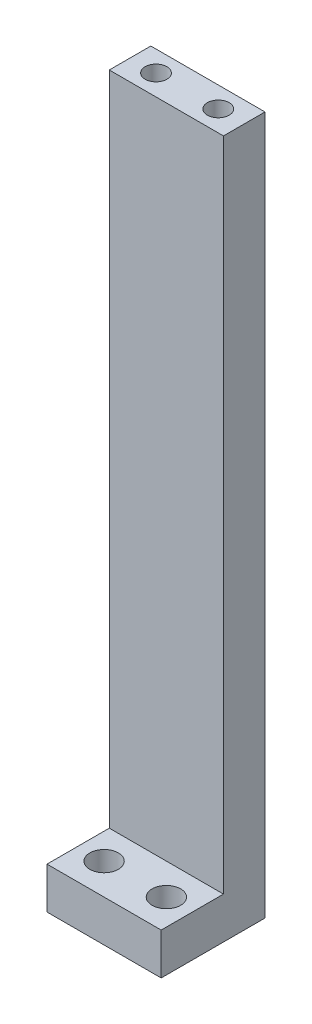
from build123d import *

# Parameters (mm, degrees)
SKETCH_1_W             = 22
SKETCH_1_H             = 134.5
EXTRUDE_1_DEPTH        = 8
HOLE_WIZARD_M5_1_D     = 4.2
HOLE_WIZARD_M5_1_DEPTH = 12.4
HOLE_WIZARD_M5_1_TIP   = 1.2618073
SKETCH_6_W             = 22
SKETCH_6_H             = 8
EXTRUDE_2_DEPTH        = 12
SKETCH_7_R             = 2.75
CUT_EXTRUDE_1_DEPTH    = 9


with BuildPart() as part:
    # 草图1 → 凸台-拉伸1 (new body)
    with BuildSketch(Plane.XY):
        with Locations((11, 67.25)):
            Rectangle(SKETCH_1_W, SKETCH_1_H)
    extrude(amount=EXTRUDE_1_DEPTH)

    # M5 螺纹孔1
    with Locations(Plane(origin=(0, 134.5, 0), x_dir=(1, 0, 0), z_dir=(0, 1, 0))):
        with Locations((17, -4), (5, -4)):
            Hole(HOLE_WIZARD_M5_1_D / 2, depth=HOLE_WIZARD_M5_1_DEPTH)
            with Locations((0, 0, -(HOLE_WIZARD_M5_1_DEPTH + HOLE_WIZARD_M5_1_TIP / 2))):  # 118° drill point
                Cone(0, HOLE_WIZARD_M5_1_D / 2, HOLE_WIZARD_M5_1_TIP, mode=Mode.SUBTRACT)

    # 草图6 → 凸台-拉伸2 (add)
    with BuildSketch(Plane.XY.offset(8)):
        with Locations((11, 4)):
            Rectangle(SKETCH_6_W, SKETCH_6_H)
    extrude(amount=EXTRUDE_2_DEPTH)

    # 草图7 → 切除-拉伸1 (cut, through all)
    with BuildSketch(Plane(origin=(0, 8, 0), x_dir=(1, 0, 0), z_dir=(0, 1, 0))):
        with Locations((5, -14)):
            Circle(SKETCH_7_R)
        with Locations((17, -14)):
            Circle(SKETCH_7_R)
    extrude(amount=-CUT_EXTRUDE_1_DEPTH, mode=Mode.SUBTRACT)


solid = part.part
